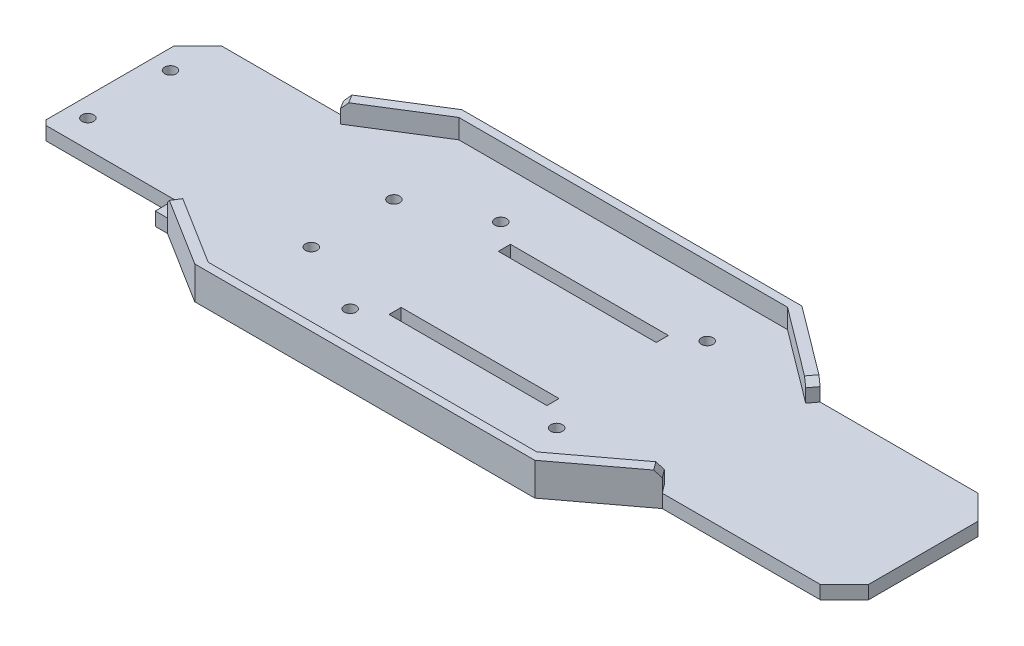
from build123d import *

# Parameters (mm, degrees)
BOSS_EXTRUDE1_DEPTH  = 5.5
CHASSIS_WALLS1_DEPTH = 8
CHAMFER1_SIZE        = 10
CHAMFER2_SIZE        = 10
CHAMFER3_SIZE        = 2.5
SKETCH4_R            = 2.4
CUT_EXTRUDE1_DEPTH   = 10
SKETCH5_W            = 55
SKETCH5_H            = 8
CUT_EXTRUDE2_DEPTH   = 10
SKETCH6_W            = 65
SKETCH6_H            = 5
CUT_EXTRUDE3_DEPTH   = 6.5


with BuildPart() as part:
    # Sketch1 → Boss-Extrude1 (new body)
    with BuildSketch(Plane(origin=(0, 0, 0), x_dir=(1, 0, 0), z_dir=(0, 1, 0))):
        Polygon((-100, 36.25), (-70, 55), (70, 55), (100, 32.5), (175, 32.5), (175, -32.5), (100, -32.5), (70, -55), (-70, -55), (-100, -36.25), (-160, -36.25), (-160, 36.25), align=None)
    extrude(amount=BOSS_EXTRUDE1_DEPTH)

    # Sketch3 → Chassis-Walls1 (add)
    with BuildSketch(Plane(origin=(0, 5.5, 0), x_dir=(1, 0, 0), z_dir=(0, 1, 0))):
        Polygon((0, 55), (-70, 55), (-100, 36.25), (-97.88000424, 32.858006784), (-67.88000424, 51.608006784), (0, 51.608006784), (67.456005088, 51.608006784), (97.456005088, 29.108006784), (100, 32.5), (70, 55), align=None)
        Polygon((67.456005088, -51.608006784), (0, -51.608006784), (-67.88000424, -51.608006784), (-97.88000424, -32.858006784), (-100, -36.25), (-70, -55), (0, -55), (70, -55), (100, -32.5), (97.456005088, -29.108006784), align=None)
    extrude(amount=CHASSIS_WALLS1_DEPTH)

    # Chamfer1
    chamfer1_edges = [part.edges().sort_by_distance(p)[0] for p in [
        (-160, 2.75, 36.25),
        (-160, 2.75, -36.25),
    ]]
    chamfer(chamfer1_edges, length=CHAMFER1_SIZE)

    # Chamfer2
    chamfer2_edges = [part.edges().sort_by_distance(p)[0] for p in [
        (175, 2.75, -32.5),
        (175, 2.75, 32.5),
    ]]
    chamfer(chamfer2_edges, length=CHAMFER2_SIZE)

    # Chamfer3
    chamfer3_edges = [part.edges().sort_by_distance(p)[0] for p in [
        (-98.94000212, 13.5, -34.554003392),
        (98.728002544, 13.5, -30.804003392),
        (-98.94000212, 13.5, 34.554003392),
        (98.728002544, 13.5, 30.804003392),
    ]]
    chamfer(chamfer3_edges, length=CHAMFER3_SIZE)

    # Sketch4 → Cut-Extrude1 (cut)
    with BuildSketch(Plane.XZ):
        with Locations((-152, 17)):
            Circle(SKETCH4_R)
        with Locations((-60, 17)):
            Circle(SKETCH4_R)
        with Locations((-60, -17)):
            Circle(SKETCH4_R)
        with Locations((-152, -17)):
            Circle(SKETCH4_R)
        with Locations((-30, 31)):
            Circle(SKETCH4_R)
        with Locations((55, 31)):
            Circle(SKETCH4_R)
        with Locations((55, -31)):
            Circle(SKETCH4_R)
        with Locations((-30, -31)):
            Circle(SKETCH4_R)
    extrude(amount=-CUT_EXTRUDE1_DEPTH, mode=Mode.SUBTRACT)

    # Sketch5 → Cut-Extrude2 (cut)
    with BuildSketch(Plane(origin=(0, 5.5, 0), x_dir=(1, 0, 0), z_dir=(0, 1, 0))):
        with Locations((-132.5, -32.25)):
            Rectangle(SKETCH5_W, SKETCH5_H)
    extrude(amount=-CUT_EXTRUDE2_DEPTH, mode=Mode.SUBTRACT)

    # Sketch6 → Cut-Extrude3 (cut, through all)
    with BuildSketch(Plane(origin=(0, 5.5, 0), x_dir=(1, 0, 0), z_dir=(0, 1, 0))):
        with Locations((12.5, 22.5)):
            Rectangle(SKETCH6_W, SKETCH6_H)
        with Locations((12.5, -22.5)):
            Rectangle(SKETCH6_W, SKETCH6_H)
    extrude(amount=-CUT_EXTRUDE3_DEPTH, mode=Mode.SUBTRACT)


solid = part.part
